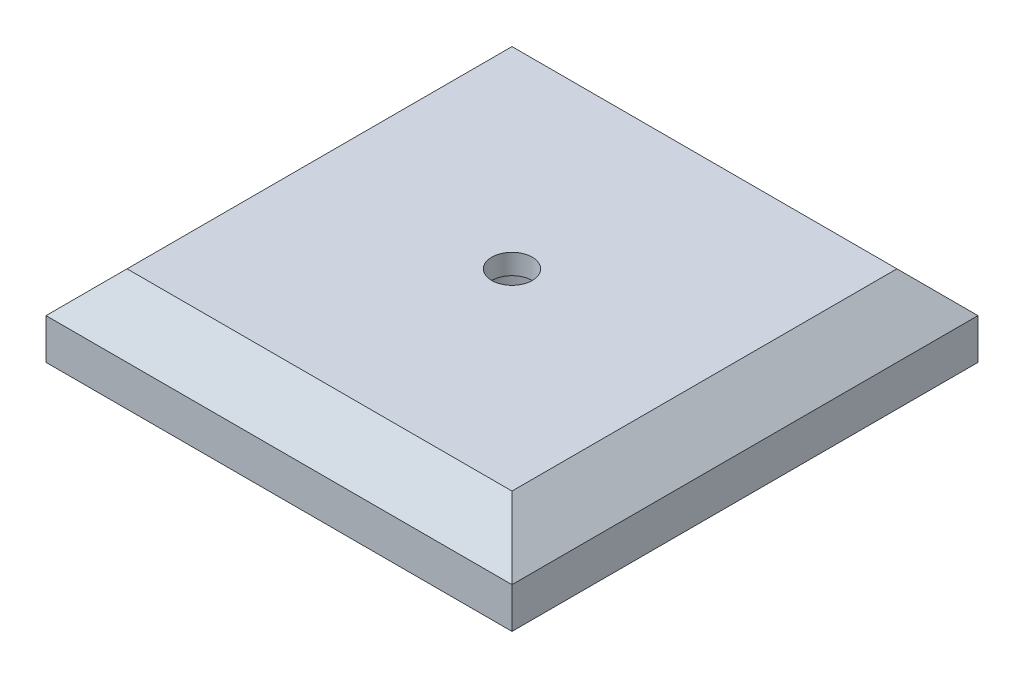
from build123d import *

# Parameters (mm, degrees)
SKETCH1_W           = 73.025
SKETCH1_H           = 73.025
BOSS_EXTRUDE1_DEPTH = 12.7
CHAMFER1_SIZE       = 6.35
SKETCH2_R           = 3.175
CUT_EXTRUDE1_DEPTH  = 3.175
SKETCH3_R           = 6.35
CUT_EXTRUDE2_DEPTH  = 9.525


with BuildPart() as part:
    # Sketch1 → Boss-Extrude1 (new body)
    with BuildSketch(Plane(origin=(0, 0, 0), x_dir=(1, 0, 0), z_dir=(0, 1, 0))):
        Rectangle(SKETCH1_W, SKETCH1_H)
    extrude(amount=BOSS_EXTRUDE1_DEPTH)

    # Chamfer1
    chamfer1_edges = [part.edges().sort_by_distance(p)[0] for p in [
        (-36.5125, 12.7, 0),
        (0, 12.7, 36.5125),
        (36.5125, 12.7, 0),
        (0, 12.7, -36.5125),
    ]]
    chamfer(chamfer1_edges, length=CHAMFER1_SIZE)

    # Sketch2 → Cut-Extrude1 (cut)
    with BuildSketch(Plane(origin=(0, 12.7, 0), x_dir=(1, 0, 0), z_dir=(0, 1, 0))):
        Circle(SKETCH2_R)
    extrude(amount=-CUT_EXTRUDE1_DEPTH, mode=Mode.SUBTRACT)

    # Sketch3 → Cut-Extrude2 (cut)
    with BuildSketch(Plane.XZ):
        Circle(SKETCH3_R)
    extrude(amount=-CUT_EXTRUDE2_DEPTH, mode=Mode.SUBTRACT)


solid = part.part
